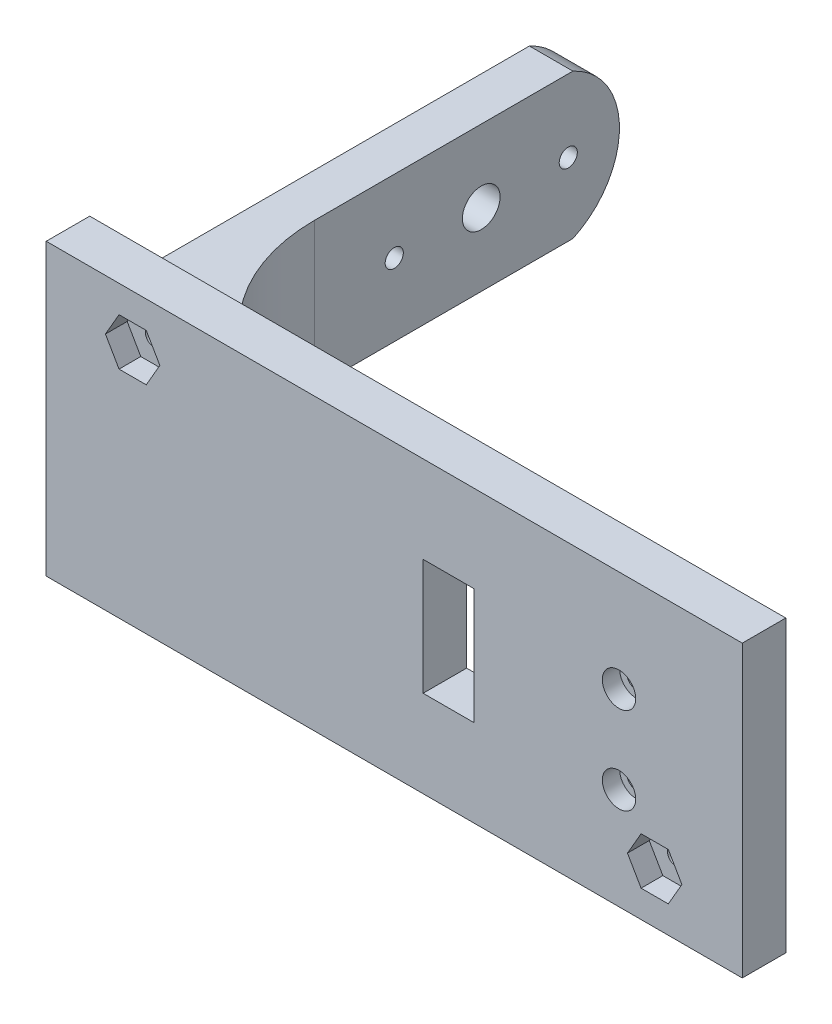
from build123d import *

# Parameters (mm, degrees)
BOSS_EXTRUDE1_DEPTH     = 25.4
SKETCH4_R               = 3.302
CUT_EXTRUDE2_DEPTH      = 7.62
SKETCH2_R               = 1.5875
SKETCH2_R_2             = 3.302
CUT_EXTRUDE3_DEPTH      = 7.62
SKETCH6_W               = 121.92
SKETCH6_H               = 12.7
BOSS_EXTRUDE2_DEPTH     = 7.62
CUT_EXTRUDE4_DEPTH      = 3.81
SKETCH10_R              = 2.921
CUT_EXTRUDE5_DEPTH      = 3.048
SKETCH11_R              = 1.5875
CUT_EXTRUDE6_DEPTH      = 96.25
CUT_EXTRUDE7_REACH      = 101.06
SKETCH12_W              = 8.89
SKETCH12_H              = 20.32
CUT_EXTRUDE8_DEPTH      = 1
CUT_EXTRUDE8_DEPTH_BACK = 122.92
SKETCH15_R              = 1.651
CUT_EXTRUDE9_DEPTH      = 8.62
SKETCH16_R              = 2.921
CUT_EXTRUDE10_DEPTH     = 3.048
SKETCH17_W              = 46.323198875
SKETCH17_H              = 88.058880532
CUT_EXTRUDE11_DEPTH     = 51.8


with BuildPart() as part:
    # Sketch1 → Boss-Extrude1 (new body)
    with BuildSketch(Plane(origin=(0, 0, 0), x_dir=(1, 0, 0), z_dir=(0, 1, 0))):
        with BuildLine():
            Line((0, 0), (0, -59.69))
            ThreePointArc((0, -59.69), (9.299359697, -82.140640303), (31.75, -91.44))
            Line((31.75, -91.44), (69.85, -91.44))
            ThreePointArc((69.85, -91.44), (92.300640303, -82.140640303), (101.6, -59.69))
            Line((101.6, -59.69), (101.6, 0))
            Line((101.6, 0), (114.3, 0))
            Line((114.3, 0), (114.3, -99.06))
            Line((114.3, -99.06), (-7.62, -99.06))
            Line((-7.62, -99.06), (-7.62, 0))
            Line((-7.62, 0), (0, 0))
        make_face()
    extrude(amount=BOSS_EXTRUDE1_DEPTH)

    # Sketch4 → Cut-Extrude2 (cut)
    with BuildSketch(Plane.ZY.offset(-101.6)):
        with Locations((30.48, 12.7)):
            Circle(SKETCH4_R)
    extrude(amount=-CUT_EXTRUDE2_DEPTH, mode=Mode.SUBTRACT)

    # Sketch2 → Cut-Extrude3 (cut)
    with BuildSketch(Plane(origin=(0, 0, 0), x_dir=(0, 0, -1), z_dir=(1, 0, 0))):
        with Locations((-15.24, 12.7)):
            Circle(SKETCH2_R)
        with Locations((-45.72, 12.7)):
            Circle(SKETCH2_R)
        with Locations((-30.48, 12.7)):
            Circle(SKETCH2_R_2)
    extrude(amount=-CUT_EXTRUDE3_DEPTH, mode=Mode.SUBTRACT)

    # Sketch6 → Boss-Extrude2 (add)
    with BuildSketch(Plane.XY.offset(99.06)):
        with Locations((53.34, 31.75)):
            Rectangle(SKETCH6_W, SKETCH6_H)
        with Locations((53.34, -6.35)):
            Rectangle(SKETCH6_W, SKETCH6_H)
    extrude(amount=-BOSS_EXTRUDE2_DEPTH)

    # Sketch7 → Cut-Extrude4 (cut)
    with BuildSketch(Plane.XY.offset(99.06)):
        Polygon((12.284426472, 29.21), (9.901413236, 33.3375), (5.135386764, 33.3375), (2.752373528, 29.21), (5.135386764, 25.0825), (9.901413236, 25.0825), align=None)
        Polygon((103.724426472, -3.81), (101.341413236, 0.3175), (96.575386764, 0.3175), (94.192373528, -3.81), (96.575386764, -7.9375), (101.341413236, -7.9375), align=None)
    extrude(amount=-CUT_EXTRUDE4_DEPTH, mode=Mode.SUBTRACT)

    # Sketch10 → Cut-Extrude5 (cut)
    with BuildSketch(Plane.ZY.offset(7.62)):
        with Locations((15.24, 12.7)):
            Circle(SKETCH10_R)
        with Locations((45.72, 12.7)):
            Circle(SKETCH10_R)
    extrude(amount=-CUT_EXTRUDE5_DEPTH, mode=Mode.SUBTRACT)

    # Sketch11 → Cut-Extrude6 (cut, through all)
    with BuildSketch(Plane.XY.offset(95.25)):
        with Locations((7.5184, 29.21)):
            Circle(SKETCH11_R)
        with Locations((98.9584, -3.81)):
            Circle(SKETCH11_R)
    extrude(amount=-CUT_EXTRUDE6_DEPTH, mode=Mode.SUBTRACT)

    # Sketch12 → Cut-Extrude7 (cut, up to next)
    with BuildSketch(Plane.XY.offset(99.06), mode=Mode.PRIVATE) as cut_extrude7_sk1:
        with Locations((62.8396, 12.7)):
            Rectangle(SKETCH12_W, SKETCH12_H)
    cut_extrude7_tool1 = extrude(cut_extrude7_sk1.sketch, amount=-CUT_EXTRUDE7_REACH, mode=Mode.PRIVATE) & part.part
    add(cut_extrude7_tool1.solids().sort_by_distance((62.8396, 12.7, 99.06))[0], mode=Mode.SUBTRACT)

    # Sketch14 → Cut-Extrude8 (cut, two sides)
    with BuildSketch(Plane.ZY.offset(7.62)) as cut_extrude8_sk:
        with BuildLine():
            Line((14.426351463, 25.4), (0, 25.4))
            Line((0, 25.4), (0, 0))
            Line((0, 0), (14.426351463, 0))
            ThreePointArc((14.426351463, 0), (6.276222595, 12.7), (14.426351463, 25.4))
        make_face()
    extrude(amount=CUT_EXTRUDE8_DEPTH, mode=Mode.SUBTRACT)
    extrude(cut_extrude8_sk.sketch, amount=-CUT_EXTRUDE8_DEPTH_BACK, mode=Mode.SUBTRACT)

    # Sketch15 → Cut-Extrude9 (cut, through all)
    with BuildSketch(Plane(origin=(0, 0, 91.44), x_dir=(-1, 0, 0), z_dir=(0, 0, -1))):
        with Locations((-92.71, 20.32)):
            Circle(SKETCH15_R)
        with Locations((-92.71, 5.08)):
            Circle(SKETCH15_R)
    extrude(amount=-CUT_EXTRUDE9_DEPTH, mode=Mode.SUBTRACT)

    # Sketch16 → Cut-Extrude10 (cut)
    with BuildSketch(Plane.XY.offset(99.06)):
        with Locations((92.71, 20.32)):
            Circle(SKETCH16_R)
        with Locations((92.71, 5.08)):
            Circle(SKETCH16_R)
    extrude(amount=-CUT_EXTRUDE10_DEPTH, mode=Mode.SUBTRACT)

    # Sketch17 → Cut-Extrude11 (cut, through all)
    with BuildSketch(Plane(origin=(0, 38.1, 0), x_dir=(1, 0, 0), z_dir=(0, 1, 0))):
        with Locations((91.138400563, -47.410559734)):
            Rectangle(SKETCH17_W, SKETCH17_H)
    extrude(amount=-CUT_EXTRUDE11_DEPTH, mode=Mode.SUBTRACT)


solid = part.part
